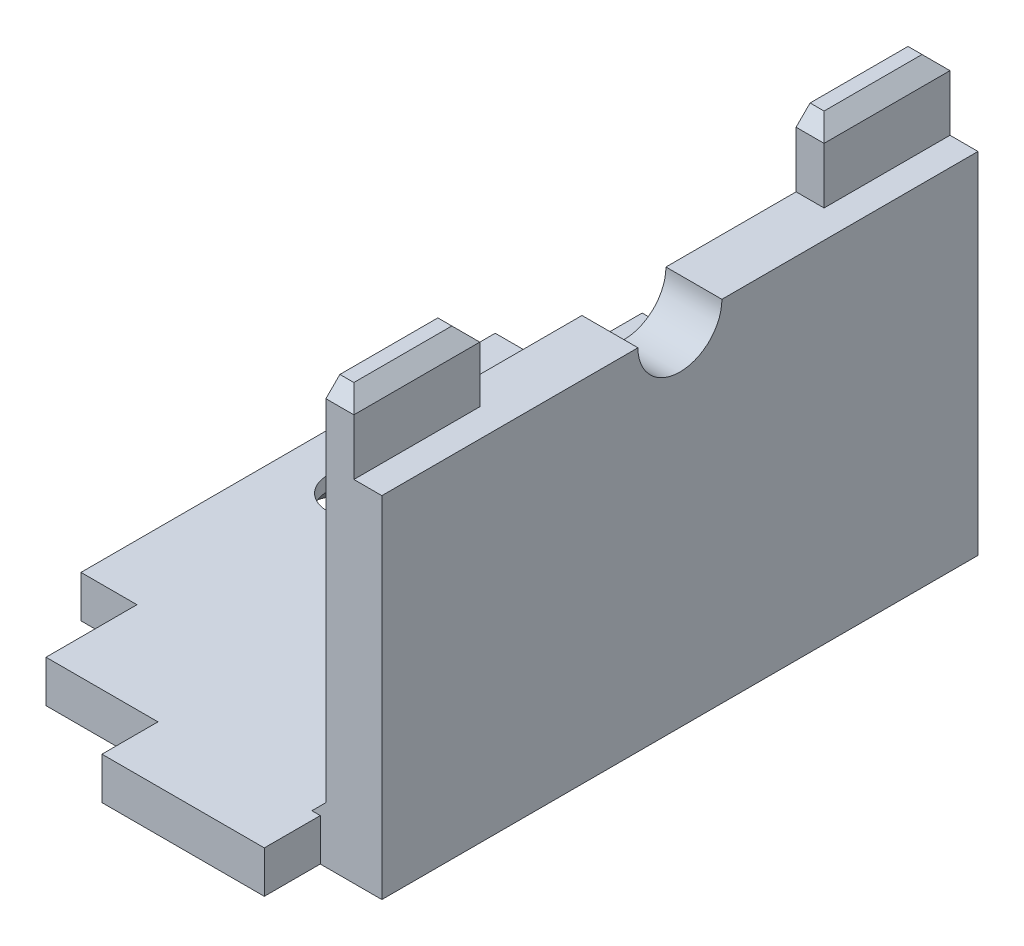
from build123d import *

# Parameters (mm, degrees)
SKETCH1_W           = 12
SKETCH1_H           = 21.3
BOSS_EXTRUDE1_DEPTH = 1.5
SKETCH2_W           = 2
SKETCH2_H           = 21.3
BOSS_EXTRUDE2_DEPTH = 11
SKETCH3_W           = 2
SKETCH3_H           = 14.8
BOSS_EXTRUDE3_DEPTH = 1.5
SKETCH4_R           = 1.5
CUT_EXTRUDE1_DEPTH  = 2
CHAMFER1_SIZE       = 0.5
CUT_EXTRUDE2_REACH  = 3.5
SKETCH5_R           = 1.1
CHAMFER2_SIZE       = 1
SKETCH6_W           = 1
SKETCH6_H           = 4.5
BOSS_EXTRUDE4_DEPTH = 2.5
CHAMFER3_SIZE       = 0.5
SKETCH7_W           = 5.8
SKETCH7_H           = 1.5
BOSS_EXTRUDE5_DEPTH = 2


with BuildPart() as part:
    # Sketch1 → Boss-Extrude1 (new body)
    with BuildSketch(Plane(origin=(0, 0, 0), x_dir=(1, 0, 0), z_dir=(0, 1, 0))):
        with Locations((6, 10.65)):
            Rectangle(SKETCH1_W, SKETCH1_H)
    extrude(amount=BOSS_EXTRUDE1_DEPTH)

    # Sketch2 → Boss-Extrude2 (add)
    with BuildSketch(Plane(origin=(0, 1.5, 0), x_dir=(1, 0, 0), z_dir=(0, 1, 0))):
        with Locations((11, 10.65)):
            Rectangle(SKETCH2_W, SKETCH2_H)
    extrude(amount=BOSS_EXTRUDE2_DEPTH)

    # Sketch3 → Boss-Extrude3 (add)
    with BuildSketch(Plane(origin=(0, 1.5, 0), x_dir=(1, 0, 0), z_dir=(0, 1, 0))):
        with Locations((-1, 10.65)):
            Rectangle(SKETCH3_W, SKETCH3_H)
    extrude(amount=-BOSS_EXTRUDE3_DEPTH)

    # Sketch4 → Cut-Extrude1 (cut)
    with BuildSketch(Plane.ZY.offset(-10)):
        with Locations((-10.65, 12.5)):
            Circle(SKETCH4_R)
    extrude(amount=-CUT_EXTRUDE1_DEPTH, mode=Mode.SUBTRACT)

    # Chamfer1
    chamfer1_edges = [part.edges().sort_by_distance(p)[0] for p in [
        (10, 1.5, -10.65),
    ]]
    chamfer(chamfer1_edges, length=CHAMFER1_SIZE)

    # Sketch5 → Cut-Extrude2 (cut, up to next)
    with BuildSketch(Plane(origin=(0, 1.5, 0), x_dir=(1, 0, 0), z_dir=(0, 1, 0)), mode=Mode.PRIVATE) as cut_extrude2_sk1:
        with Locations((0.5, 10.65)):
            Circle(SKETCH5_R)
    cut_extrude2_tool1 = extrude(cut_extrude2_sk1.sketch, amount=-CUT_EXTRUDE2_REACH, mode=Mode.PRIVATE) & part.part
    add(cut_extrude2_tool1.solids().sort_by_distance((0.5, 1.5, -10.65))[0], mode=Mode.SUBTRACT)

    # Chamfer2
    chamfer2_edges = [part.edges().sort_by_distance(p)[0] for p in [
        (-0.6, 0, -10.65),
    ]]
    chamfer(chamfer2_edges, length=CHAMFER2_SIZE)

    # Sketch6 → Boss-Extrude4 (add)
    with BuildSketch(Plane(origin=(0, 12.5, 0), x_dir=(1, 0, 0), z_dir=(0, 1, 0))):
        with Locations((10.5, 2.25)):
            Rectangle(SKETCH6_W, SKETCH6_H)
        with Locations((10.5, 19.05)):
            Rectangle(SKETCH6_W, SKETCH6_H)
    extrude(amount=BOSS_EXTRUDE4_DEPTH)

    # Chamfer3
    chamfer3_edges = [part.edges().sort_by_distance(p)[0] for p in [
        (10.5, 15, -21.3),
        (11, 15, -19.05),
        (10.5, 15, -16.8),
        (10.5, 15, -4.5),
        (11, 15, -2.25),
        (10.5, 15, 0),
    ]]
    chamfer(chamfer3_edges, length=CHAMFER3_SIZE)

    # Sketch7 → Boss-Extrude5 (add)
    with BuildSketch(Plane.XY):
        with Locations((6.9, 0.75)):
            Rectangle(SKETCH7_W, SKETCH7_H)
    extrude(amount=BOSS_EXTRUDE5_DEPTH)


solid = part.part
